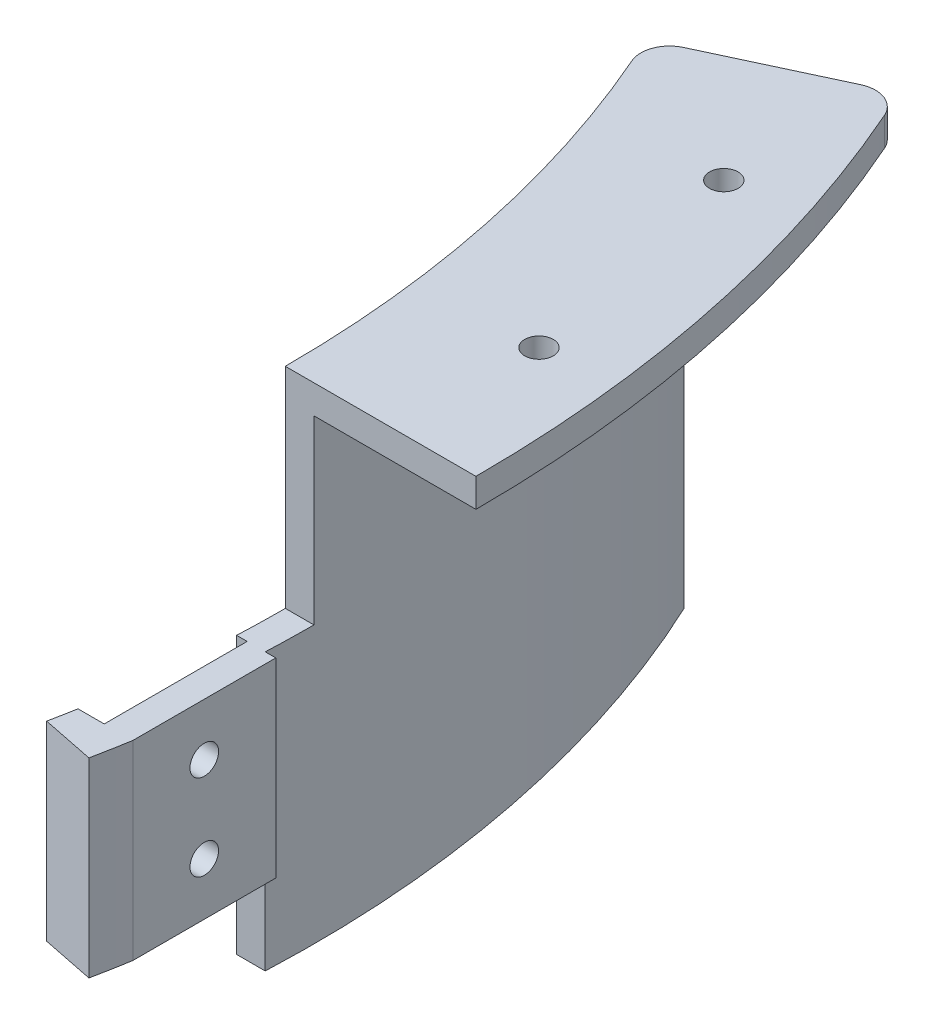
from build123d import *

# Parameters (mm, degrees)
EXTRUDE_1_DEPTH      = 64
CUT_EXTRUDE_1_DEPTH  = 64
SKETCH_4_W           = 3
SKETCH_4_H           = 15
CUT_EXTRUDE_2_DEPTH  = 84
CUT_EXTRUDE_3_DEPTH  = 61
CUT_EXTRUDE_4_DEPTH  = 22
CUT_EXTRUDE_5_DEPTH  = 22
FILLET_1_R           = 3
SKETCH_8_R           = 1.5
CUT_EXTRUDE_8_DEPTH  = 10
CUT_EXTRUDE_9_DEPTH  = 13
SKETCH_10_R          = 1.5
CUT_EXTRUDE_10_DEPTH = 10
FILLET_2_R           = 3


with BuildPart() as part:
    # 草图2 → 凸台-拉伸1 (new body)
    with BuildSketch(Plane(origin=(0, 0, 0), x_dir=(1, 0, 0), z_dir=(0, 1, 0))):
        with BuildLine():
            Line((0, 0), (122.35155125, 57.053465335))
            ThreePointArc((122.35155125, 57.053465335), (134.052652215, 15.965163138), (132.328890593, -26.721989344))
            Line((132.328890593, -26.721989344), (0, 0))
        make_face()
    extrude(amount=-EXTRUDE_1_DEPTH)

    # 草图3 → 切除-拉伸1 (cut)
    with BuildSketch(Plane(origin=(0, 0, 0), x_dir=(1, 0, 0), z_dir=(0, 1, 0))):
        with BuildLine():
            Line((0, 0), (104.225395509, 48.6011001))
            ThreePointArc((104.225395509, 48.6011001), (114.193000035, 13.599953785), (112.724610505, -22.763176108))
            Line((112.724610505, -22.763176108), (0, 0))
        make_face()
    extrude(amount=-CUT_EXTRUDE_1_DEPTH, mode=Mode.SUBTRACT)

    # 草图4 → 切除-拉伸2 (cut)
    with BuildSketch(Plane(origin=(0, 0, 0), x_dir=(1, 0, 0), z_dir=(0, 1, 0))):
        with Locations((114.5, -12.5)):
            Rectangle(SKETCH_4_W, SKETCH_4_H)
    extrude(amount=-CUT_EXTRUDE_2_DEPTH, mode=Mode.SUBTRACT)

    # 草图5 → 切除-拉伸3 (cut)
    with BuildSketch(Plane.XZ.offset(64)):
        with BuildLine():
            Line((132.328890593, 26.721989344), (118.281412986, 23.885295518))
            ThreePointArc((118.281412986, 23.885295518), (118.656610088, 21.945589136), (119, 20))
            Line((119, 20), (119, 5))
            Line((119, 5), (117.894020205, 5))
            ThreePointArc((117.894020205, 5), (115.718279593, -23.092851014), (106.94431887, -49.868954885))
            Line((106.94431887, -49.868954885), (122.35155125, -57.053465335))
            ThreePointArc((122.35155125, -57.053465335), (134.052652215, -15.965163138), (132.328890593, 26.721989344))
        make_face()
    extrude(amount=-CUT_EXTRUDE_3_DEPTH, mode=Mode.SUBTRACT)

    # 草图6 → 切除-拉伸4 (cut)
    with BuildSketch(Plane(origin=(0, 0, 0), x_dir=(1, 0, 0), z_dir=(0, 1, 0))):
        with BuildLine():
            Line((135, 0), (115, 0))
            ThreePointArc((115, 0), (114.972810018, -2.500591226), (114.891252931, -5))
            Line((114.891252931, -5), (116, -5))
            Line((116, -5), (116, -20))
            Line((116, -20), (113.247516529, -20))
            ThreePointArc((113.247516529, -20), (112.994510197, -21.383186511), (112.724610505, -22.763176108))
            Line((112.724610505, -22.763176108), (132.328890593, -26.721989344))
            ThreePointArc((132.328890593, -26.721989344), (134.330562848, -13.427579268), (135, 0))
        make_face()
    extrude(amount=-CUT_EXTRUDE_4_DEPTH, mode=Mode.SUBTRACT)

    # 草图7 → 切除-拉伸5 (cut)
    with BuildSketch(Plane.XZ.offset(64)):
        with BuildLine():
            Line((116, 5), (119, 5))
            Line((119, 5), (119, 20))
            ThreePointArc((119, 20), (118.656610088, 21.945589136), (118.281412986, 23.885295518))
            Line((118.281412986, 23.885295518), (112.724610505, 22.763176108))
            ThreePointArc((112.724610505, 22.763176108), (112.994510197, 21.383186511), (113.247516529, 20))
            Line((113.247516529, 20), (116, 20))
            Line((116, 20), (116, 5))
        make_face()
    extrude(amount=-CUT_EXTRUDE_5_DEPTH, mode=Mode.SUBTRACT)

    # 圆角1
    fillet_1_edges = [part.edges().sort_by_distance(p)[0] for p in [
        (122.35155125, -1.5, -57.053465335),
    ]]
    fillet(fillet_1_edges, radius=FILLET_1_R)

    # 草图8 → 切除-拉伸8 (cut)
    with BuildSketch(Plane(origin=(119, 0, 0), x_dir=(0, 0, -1), z_dir=(1, 0, 0))):
        with Locations((-12.5, -27.5)):
            Circle(SKETCH_8_R)
        with Locations((-12.5, -36.5)):
            Circle(SKETCH_8_R)
    extrude(amount=-CUT_EXTRUDE_8_DEPTH, mode=Mode.SUBTRACT)

    # 草图9 → 切除-拉伸9 (cut)
    with BuildSketch(Plane.XZ.offset(64)):
        with BuildLine():
            Line((106.94431887, -49.868954885), (104.225395509, -48.6011001))
            ThreePointArc((104.225395509, -48.6011001), (112.788722348, -22.443353384), (114.891252931, 5))
            Line((114.891252931, 5), (117.894020205, 5))
            ThreePointArc((117.894020205, 5), (115.718279593, -23.092851014), (106.94431887, -49.868954885))
        make_face()
    extrude(amount=-CUT_EXTRUDE_9_DEPTH, mode=Mode.SUBTRACT)

    # 草图10 → 切除-拉伸10 (cut)
    with BuildSketch(Plane(origin=(0, 0, 0), x_dir=(1, 0, 0), z_dir=(0, 1, 0))):
        with Locations((121.091047045, 39.915013787)):
            Circle(SKETCH_10_R)
        with Locations((126.614572621, 15)):
            Circle(SKETCH_10_R)
    extrude(amount=-CUT_EXTRUDE_10_DEPTH, mode=Mode.SUBTRACT)

    # 圆角2
    fillet_2_edges = [part.edges().sort_by_distance(p)[0] for p in [
        (104.225395509, -25.5, -48.6011001),
    ]]
    fillet(fillet_2_edges, radius=FILLET_2_R)


solid = part.part
